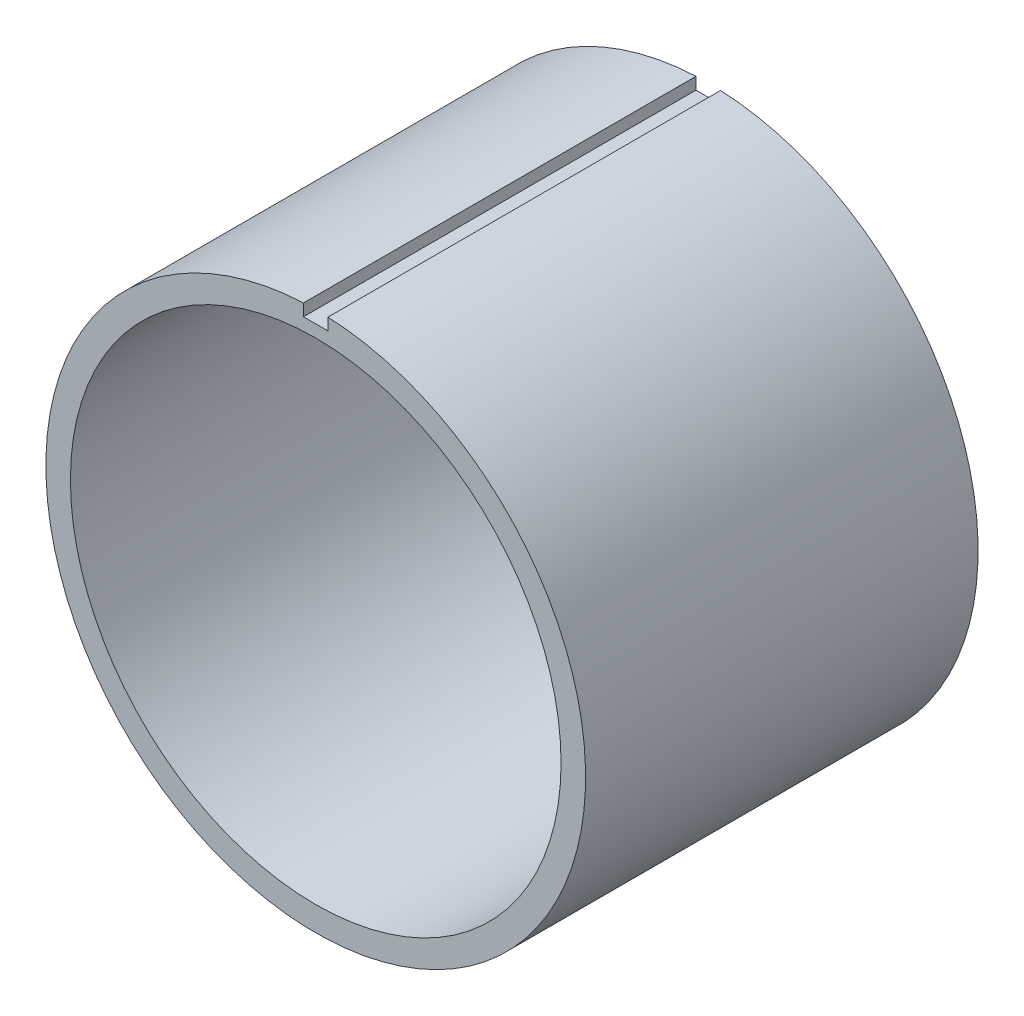
from build123d import *
from build123d.topology import SkipClean

# Parameters (mm, degrees)
SKETCH1_R           = 110
SKETCH1_R_2         = 100
BOSS_EXTRUDE1_DEPTH = 150
BOSS_EXTRUDE2_START = 10
SKETCH2_R           = 110
SKETCH2_R_2         = 40
BOSS_EXTRUDE2_DEPTH = 10
SKETCH4_W           = 10
SKETCH4_H           = 160
CUT_EXTRUDE1_DEPTH  = 10


with BuildPart() as part:
    # Sketch1 → Boss-Extrude1 (new body)
    with BuildSketch(Plane.XY):
        Circle(SKETCH1_R)
        Circle(SKETCH1_R_2, mode=Mode.SUBTRACT)
    extrude(amount=BOSS_EXTRUDE1_DEPTH)

    # Sketch2 → Boss-Extrude2 (add)
    # profile 1 of 2: a face of its own
    with BuildSketch(Plane(origin=(0, 0, 0), x_dir=(-1, 0, 0), z_dir=(0, 0, -1)).offset(BOSS_EXTRUDE2_START)):
        Circle(SKETCH2_R)
        with BuildLine():
            ThreePointArc((-99.874921777, 5), (-68.92024376, 72.456883731), (0, 100))
            ThreePointArc((0, 100), (2.500782106, 99.968725554), (5, 99.874921777))
            ThreePointArc((5, 99.874921777), (72.456883731, 68.92024376), (100, 0))
            ThreePointArc((100, 0), (99.968725554, -2.500782106), (99.874921777, -5))
            ThreePointArc((99.874921777, -5), (68.92024376, -72.456883731), (0, -100))
            ThreePointArc((0, -100), (-2.500782106, -99.968725554), (-5, -99.874921777))
            ThreePointArc((-5, -99.874921777), (-72.456883731, -68.92024376), (-100, 0))
            ThreePointArc((-100, 0), (-99.968725554, 2.500782106), (-99.874921777, 5))
        make_face(mode=Mode.SUBTRACT)
    # profile 2 of 2: a face of its own
    with BuildSketch(Plane(origin=(0, 0, 0), x_dir=(-1, 0, 0), z_dir=(0, 0, -1)).offset(BOSS_EXTRUDE2_START)):
        with BuildLine():
            ThreePointArc((0, 45), (-30, 33.541019662), (-44.72135955, 5))
            Line((-44.72135955, 5), (-99.874921777, 5))
            Line((-99.874921777, 5), (-100, 0))
            Line((-100, 0), (-45, 0))
            ThreePointArc((-45, 0), (-33.541019662, -30), (-5, -44.72135955))
            Line((-5, -44.72135955), (-5, -99.874921777))
            Line((-5, -99.874921777), (0, -100))
            Line((0, -100), (0, -45))
            ThreePointArc((0, -45), (30, -33.541019662), (44.72135955, -5))
            Line((44.72135955, -5), (99.874921777, -5))
            Line((99.874921777, -5), (100, 0))
            Line((100, 0), (45, 0))
            ThreePointArc((45, 0), (33.541019662, 30), (5, 44.72135955))
            Line((5, 44.72135955), (5, 99.874921777))
            Line((5, 99.874921777), (0, 100))
            Line((0, 100), (0, 45))
        make_face()
        Circle(SKETCH2_R_2, mode=Mode.SUBTRACT)
    extrude(amount=-BOSS_EXTRUDE2_DEPTH)


with BuildPart() as boss_extrude2_piece_1:
    # of the separate pieces the step leaves, piece 1, a body of its own (boss_extrude2_pieces)
    add(part.part.solids().sort_by_distance((110, 0, 0))[0])

    # Sketch4 → Cut-Extrude1 (cut)
    with SkipClean():  # the faces are left unmerged after this step: merging them gives an invalid solid
        with BuildSketch(Plane(origin=(0, 105, 0), x_dir=(-1, 0, 0), z_dir=(0, 1, 0))):
            with Locations((0, 70)):
                Rectangle(SKETCH4_W, SKETCH4_H)
        extrude(amount=CUT_EXTRUDE1_DEPTH, mode=Mode.SUBTRACT)


with BuildPart() as boss_extrude2_piece_2:
    # of the separate pieces the step leaves, piece 2, a body of its own (boss_extrude2_pieces)
    add(part.part.solids().sort_by_distance((5, -44.72135955, -10))[0])


solid = Compound([boss_extrude2_piece_1.part, boss_extrude2_piece_2.part])
